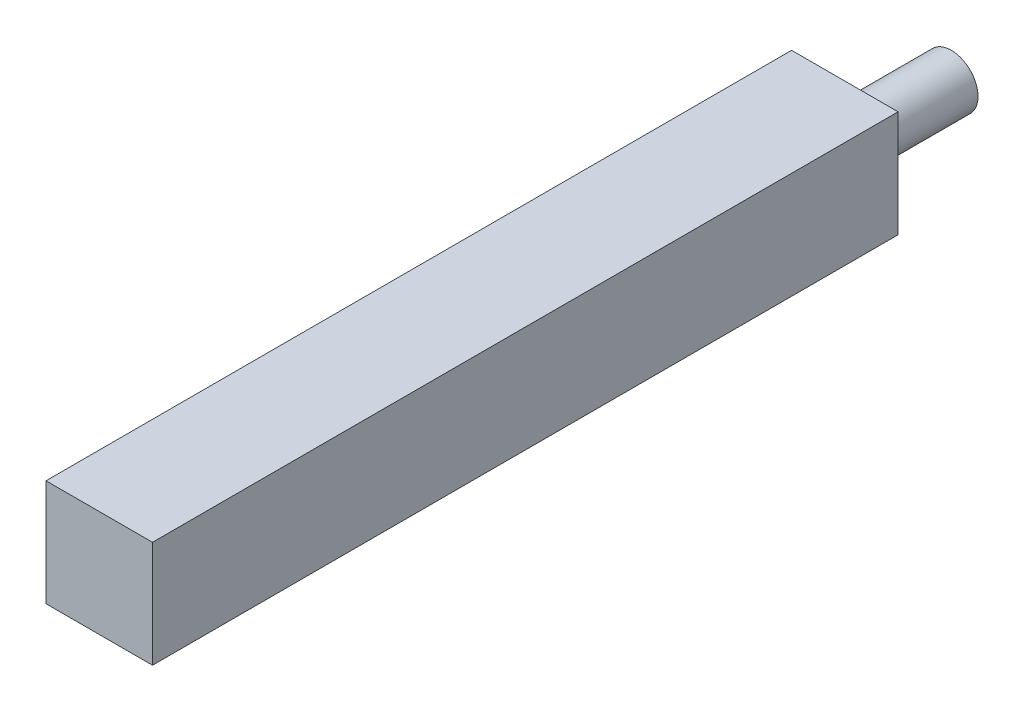
from build123d import *

# Parameters (mm, degrees)
SKETCH1_W           = 100
SKETCH1_H           = 100
BOSS_EXTRUDE1_DEPTH = 700
SKETCH2_R           = 25
BOSS_EXTRUDE2_DEPTH = 100


with BuildPart() as part:
    # Sketch1 → Boss-Extrude1 (new body)
    with BuildSketch(Plane.XY):
        with Locations((50, 50)):
            Rectangle(SKETCH1_W, SKETCH1_H)
    extrude(amount=BOSS_EXTRUDE1_DEPTH)

    # Sketch2 → Boss-Extrude2 (add)
    with BuildSketch(Plane.XY):
        with Locations((50, 50)):
            Circle(SKETCH2_R)
    extrude(amount=-BOSS_EXTRUDE2_DEPTH)


solid = part.part
